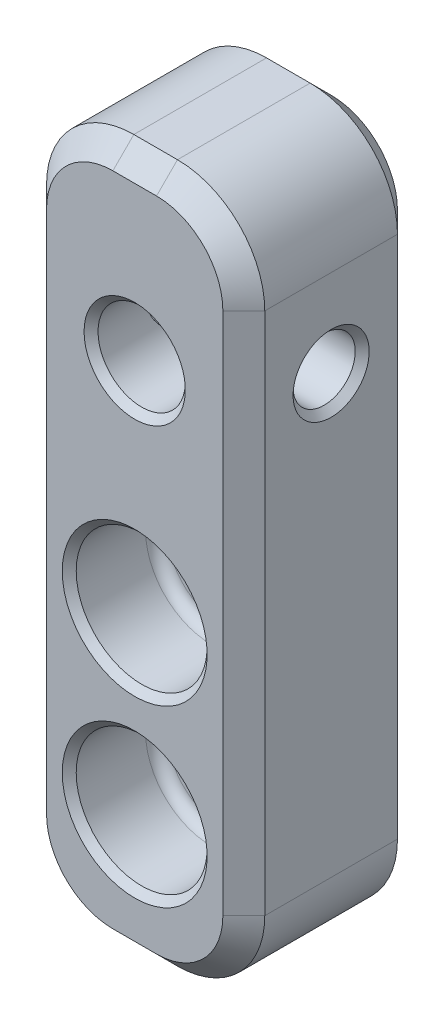
from build123d import *

# Parameters (mm, degrees)
SKETCH1_W                                           = 7.9375
SKETCH1_H                                           = 25.4
BOSS_EXTRUDE1_DEPTH                                 = 3.175
F_1_8_0_125_DIAMETER_HOLE1_D                        = 3.175
CBORE_FOR_2_BINDING_HEAD_MACHINE_SCREW1_D           = 2.4384
CBORE_FOR_2_BINDING_HEAD_MACHINE_SCREW1_CBORE_D     = 4.7625
CBORE_FOR_2_BINDING_HEAD_MACHINE_SCREW1_CBORE_DEPTH = 3.175
F_4_40_TAPPED_HOLE1_D                               = 2.2606
FILLET1_R                                           = 3.175
FILLET2_R                                           = 0.396875
CHAMFER2_SIZE                                       = 0.762
CHAMFER3_SIZE                                       = 0.254


with BuildPart() as part:
    # Sketch1 → Boss-Extrude1 (new body, symmetric)
    with BuildSketch(Plane.XY):
        Rectangle(SKETCH1_W, SKETCH1_H)
    extrude(amount=BOSS_EXTRUDE1_DEPTH, both=True)

    # 1/8 (0.125) Diameter Hole1 (through all)
    with Locations(Plane.XY.offset(3.175)):
        with Locations((0, 6.35)):
            Hole(F_1_8_0_125_DIAMETER_HOLE1_D / 2)

    # CBORE for #2 Binding Head Machine Screw1 (through all)
    with Locations(Plane.XY.offset(3.175)):
        with Locations((0, -1.5875), (0, -7.9375)):
            CounterBoreHole(CBORE_FOR_2_BINDING_HEAD_MACHINE_SCREW1_D / 2, CBORE_FOR_2_BINDING_HEAD_MACHINE_SCREW1_CBORE_D / 2, CBORE_FOR_2_BINDING_HEAD_MACHINE_SCREW1_CBORE_DEPTH)

    # #4-40 Tapped Hole1 (through all)
    with Locations(Plane.ZY.offset(3.96875)):
        with Locations((0, 6.35)):
            Hole(F_4_40_TAPPED_HOLE1_D / 2)

    # Fillet1
    fillet1_edges = [part.edges().sort_by_distance(p)[0] for p in [
        (-3.96875, -12.7, 0),
        (3.96875, -12.7, 0),
        (3.96875, 12.7, 0),
        (-3.96875, 12.7, 0),
    ]]
    fillet(fillet1_edges, radius=FILLET1_R)

    # Fillet2
    fillet2_edges = [part.edges().sort_by_distance(p)[0] for p in [
        (-2.38125, -7.9375, 0),
        (-2.38125, -1.5875, 0),
    ]]
    fillet(fillet2_edges, radius=FILLET2_R)

    # Chamfer2
    chamfer2_edges = [part.edges().sort_by_distance(p)[0] for p in [
        (0, 12.7, -3.175),
        (0, 12.7, 3.175),
        (-3.96875, 0, -3.175),
        (3.96875, 0, -3.175),
        (0, -12.7, -3.175),
        (-3.03881403, 11.77006403, -3.175),
        (-3.03881403, -11.77006403, -3.175),
        (3.03881403, -11.77006403, -3.175),
        (3.03881403, 11.77006403, -3.175),
        (3.96875, 0, 3.175),
        (-3.96875, 0, 3.175),
        (0, -12.7, 3.175),
        (-3.03881403, 11.77006403, 3.175),
        (-3.03881403, -11.77006403, 3.175),
        (3.03881403, -11.77006403, 3.175),
        (3.03881403, 11.77006403, 3.175),
    ]]
    chamfer(chamfer2_edges, length=CHAMFER2_SIZE)

    # Chamfer3
    chamfer3_edges = [part.edges().sort_by_distance(p)[0] for p in [
        (1.5875, 6.35, 3.175),
        (1.5875, 6.35, -3.175),
        (-2.38125, -7.9375, 3.175),
        (1.2192, -7.9375, -3.175),
        (1.2192, -7.9375, 0),
        (-2.38125, -1.5875, 3.175),
        (1.2192, -1.5875, -3.175),
        (1.2192, -1.5875, 0),
        (3.96875, 6.35, 1.1303),
        (-3.96875, 6.35, 1.1303),
    ]]
    chamfer(chamfer3_edges, length=CHAMFER3_SIZE)


solid = part.part
